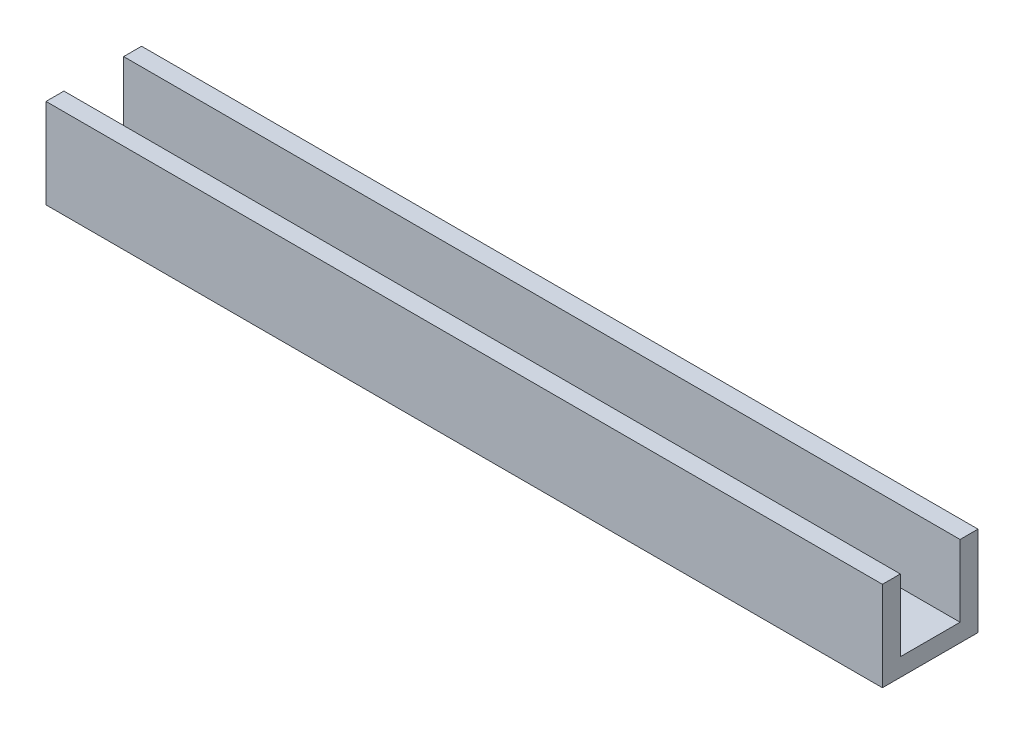
from build123d import *

# Parameters (mm, degrees)
SKETCH3_W           = 140
SKETCH3_H           = 10
BOSS_EXTRUDE2_DEPTH = 3
SKETCH3_3_W         = 140
SKETCH3_3_H         = 3
BOSS_EXTRUDE3_DEPTH = 15


with BuildPart() as part:
    # Sketch3 → Boss-Extrude2 (new body)
    with BuildSketch(Plane(origin=(0, 0, 0), x_dir=(1, 0, 0), z_dir=(0, 1, 0))):
        Rectangle(SKETCH3_W, SKETCH3_H)
    extrude(amount=BOSS_EXTRUDE2_DEPTH)

    # Sketch3_3 → Boss-Extrude3 (add)
    with BuildSketch(Plane(origin=(0, 0, 0), x_dir=(1, 0, 0), z_dir=(0, 1, 0))):
        with Locations((0, -6.5)):
            Rectangle(SKETCH3_3_W, SKETCH3_3_H)
        with Locations((0, 6.5)):
            Rectangle(SKETCH3_3_W, SKETCH3_3_H)
    extrude(amount=BOSS_EXTRUDE3_DEPTH)


solid = part.part
